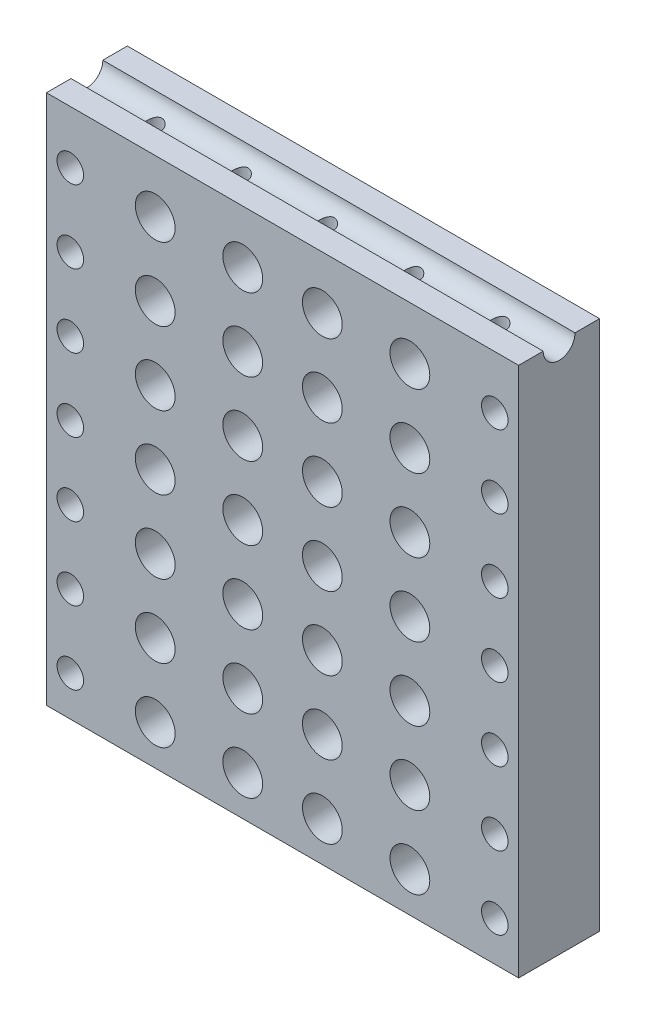
from build123d import *

# Parameters (mm, degrees)
SKETCH1_W           = 356
SKETCH1_H           = 400
BOSS_EXTRUDE1_DEPTH = 30.5
SKETCH4_R           = 10
SKETCH4_R_2         = 6
BOSS_EXTRUDE2_DEPTH = 400
CUT_EXTRUDE1_DEPTH  = 357
SKETCH4_2_R         = 6
CUT_EXTRUDE2_DEPTH  = 401
SKETCH4_3_R         = 6
CUT_EXTRUDE3_DEPTH  = 401.0000001
SKETCH8_R           = 15
SKETCH8_R_2         = 10
CUT_EXTRUDE4_DEPTH  = 62


with BuildPart() as part:
    # Sketch1 → Boss-Extrude1 (new body, symmetric)
    with BuildSketch(Plane.XY):
        Rectangle(SKETCH1_W, SKETCH1_H)
    extrude(amount=BOSS_EXTRUDE1_DEPTH, both=True)

    # Sketch4 → Boss-Extrude2 (add, through all)
    with BuildSketch(Plane(origin=(0, 200, 0), x_dir=(1, 0, 0), z_dir=(0, 1, 0))):
        with Locations((-128, 0.5)):
            Circle(SKETCH4_R)
        with Locations((-128, 0.5)):
            Circle(SKETCH4_R_2, mode=Mode.SUBTRACT)
        with Locations((-63, 0.5)):
            Circle(SKETCH4_R)
        with Locations((-63, 0.5)):
            Circle(SKETCH4_R_2, mode=Mode.SUBTRACT)
        with Locations((2, 0.5)):
            Circle(SKETCH4_R)
        with Locations((2, 0.5)):
            Circle(SKETCH4_R_2, mode=Mode.SUBTRACT)
        with Locations((67, 0.5)):
            Circle(SKETCH4_R)
        with Locations((67, 0.5)):
            Circle(SKETCH4_R_2, mode=Mode.SUBTRACT)
        with Locations((132, 0.5)):
            Circle(SKETCH4_R)
        with Locations((132, 0.5)):
            Circle(SKETCH4_R_2, mode=Mode.SUBTRACT)
    extrude(amount=-BOSS_EXTRUDE2_DEPTH)

    # Sketch6 → Cut-Extrude1 (cut, through all)
    with BuildSketch(Plane(origin=(178, 0, 0), x_dir=(0, 0, -1), z_dir=(1, 0, 0))):
        with BuildLine():
            Line((-12, 200), (12, 200))
            ThreePointArc((12, 200), (0, 188), (-12, 200))
        make_face()
    extrude(amount=-CUT_EXTRUDE1_DEPTH, mode=Mode.SUBTRACT)

    # Sketch4_2 → Cut-Extrude2 (cut, through all)
    with BuildSketch(Plane(origin=(0, 200, 0), x_dir=(1, 0, 0), z_dir=(0, 1, 0))):
        with Locations((-128, 0.5)):
            Circle(SKETCH4_2_R)
    extrude(amount=-CUT_EXTRUDE2_DEPTH, mode=Mode.SUBTRACT)

    # Sketch4_3 → Cut-Extrude3 (cut, through all)
    with BuildSketch(Plane(origin=(0, 200, 0), x_dir=(1, 0, 0), z_dir=(0, 1, 0))):
        with Locations((-128, 0.5)):
            Circle(SKETCH4_3_R)
        with Locations((-63, 0.5)):
            Circle(SKETCH4_3_R)
        with Locations((2, 0.5)):
            Circle(SKETCH4_3_R)
        with Locations((67, 0.5)):
            Circle(SKETCH4_3_R)
        with Locations((132, 0.5)):
            Circle(SKETCH4_3_R)
    extrude(amount=-CUT_EXTRUDE3_DEPTH, mode=Mode.SUBTRACT)

    # Sketch8 → Cut-Extrude4 (cut, through all)
    with BuildSketch(Plane.XY.offset(30.5)):
        with Locations((-30, 160)):
            Circle(SKETCH8_R)
        with Locations((-30, 105)):
            Circle(SKETCH8_R)
        with Locations((-30, 50)):
            Circle(SKETCH8_R)
        with Locations((-30, -5)):
            Circle(SKETCH8_R)
        with Locations((-30, -60)):
            Circle(SKETCH8_R)
        with Locations((-30, -115)):
            Circle(SKETCH8_R)
        with Locations((-30, -170)):
            Circle(SKETCH8_R)
        with Locations((30, -170)):
            Circle(SKETCH8_R)
        with Locations((30, -115)):
            Circle(SKETCH8_R)
        with Locations((30, -60)):
            Circle(SKETCH8_R)
        with Locations((30, -5)):
            Circle(SKETCH8_R)
        with Locations((30, 50)):
            Circle(SKETCH8_R)
        with Locations((30, 105)):
            Circle(SKETCH8_R)
        with Locations((30, 160)):
            Circle(SKETCH8_R)
        with Locations((-96, -170)):
            Circle(SKETCH8_R)
        with Locations((-96, -115)):
            Circle(SKETCH8_R)
        with Locations((-96, -60)):
            Circle(SKETCH8_R)
        with Locations((-96, -5)):
            Circle(SKETCH8_R)
        with Locations((-96, 50)):
            Circle(SKETCH8_R)
        with Locations((-96, 105)):
            Circle(SKETCH8_R)
        with Locations((-96, 160)):
            Circle(SKETCH8_R)
        with Locations((96, 160)):
            Circle(SKETCH8_R)
        with Locations((96, 105)):
            Circle(SKETCH8_R)
        with Locations((96, 50)):
            Circle(SKETCH8_R)
        with Locations((96, -5)):
            Circle(SKETCH8_R)
        with Locations((96, -60)):
            Circle(SKETCH8_R)
        with Locations((96, -115)):
            Circle(SKETCH8_R)
        with Locations((96, -170)):
            Circle(SKETCH8_R)
        with Locations((-160, 160)):
            Circle(SKETCH8_R_2)
        with Locations((-160, 105)):
            Circle(SKETCH8_R_2)
        with Locations((-160, 50)):
            Circle(SKETCH8_R_2)
        with Locations((-160, -5)):
            Circle(SKETCH8_R_2)
        with Locations((-160, -60)):
            Circle(SKETCH8_R_2)
        with Locations((-160, -115)):
            Circle(SKETCH8_R_2)
        with Locations((-160, -170)):
            Circle(SKETCH8_R_2)
        with Locations((160, -170)):
            Circle(SKETCH8_R_2)
        with Locations((160, -115)):
            Circle(SKETCH8_R_2)
        with Locations((160, -60)):
            Circle(SKETCH8_R_2)
        with Locations((160, -5)):
            Circle(SKETCH8_R_2)
        with Locations((160, 50)):
            Circle(SKETCH8_R_2)
        with Locations((160, 105)):
            Circle(SKETCH8_R_2)
        with Locations((160, 160)):
            Circle(SKETCH8_R_2)
    extrude(amount=-CUT_EXTRUDE4_DEPTH, mode=Mode.SUBTRACT)


solid = part.part
